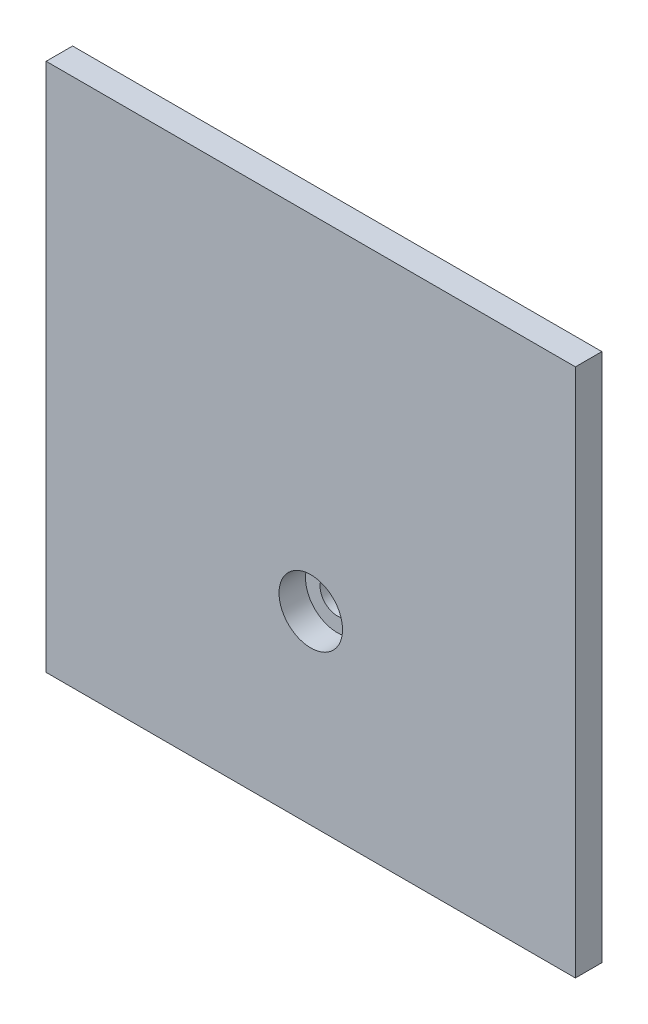
from build123d import *

# Parameters (mm, degrees)
ESQUISSE1_W             = 100
ESQUISSE1_H             = 100
BOSS_EXTRU_1_DEPTH      = 5
BOSS_EXTRU_2_DEPTH      = 30
ENL_V_MAT_EXTRU_1_DEPTH = 30
ESQUISSE6_R             = 3.25
ENL_V_MAT_EXTRU_2_DEPTH = 35
ESQUISSE7_R             = 6
ENL_V_MAT_EXTRU_3_DEPTH = 5


with BuildPart() as part:
    # Esquisse1 → Boss.-Extru.1 (new body)
    with BuildSketch(Plane.XY):
        Rectangle(ESQUISSE1_W, ESQUISSE1_H)
    extrude(amount=BOSS_EXTRU_1_DEPTH)

    # Esquisse4 → Boss.-Extru.2 (add)
    with BuildSketch(Plane(origin=(0, 0, 0), x_dir=(-1, 0, 0), z_dir=(0, 0, -1))):
        with BuildLine():
            Line((-15, 45), (15, 45))
            Line((15, 45), (15, -15))
            ThreePointArc((15, -15), (0, -30), (-15, -15))
            Line((-15, -15), (-15, 45))
        make_face()
    extrude(amount=BOSS_EXTRU_2_DEPTH)

    # Esquisse5 → Enlèv. mat.-Extru.1 (cut)
    with BuildSketch(Plane(origin=(15, 0, 0), x_dir=(0, 0, -1), z_dir=(1, 0, 0))):
        Polygon((0, 45), (30, 0), (30, 45), align=None)
    extrude(amount=-ENL_V_MAT_EXTRU_1_DEPTH, mode=Mode.SUBTRACT)

    # Esquisse6 → Enlèv. mat.-Extru.2 (cut)
    with BuildSketch(Plane(origin=(0, 0, -30), x_dir=(-1, 0, 0), z_dir=(0, 0, -1))):
        with Locations((0, -15)):
            Circle(ESQUISSE6_R)
    extrude(amount=-ENL_V_MAT_EXTRU_2_DEPTH, mode=Mode.SUBTRACT)

    # Esquisse7 → Enlèv. mat.-Extru.3 (cut)
    with BuildSketch(Plane.XY.offset(5)):
        with Locations((0, -15)):
            Circle(ESQUISSE7_R)
    extrude(amount=-ENL_V_MAT_EXTRU_3_DEPTH, mode=Mode.SUBTRACT)


solid = part.part
